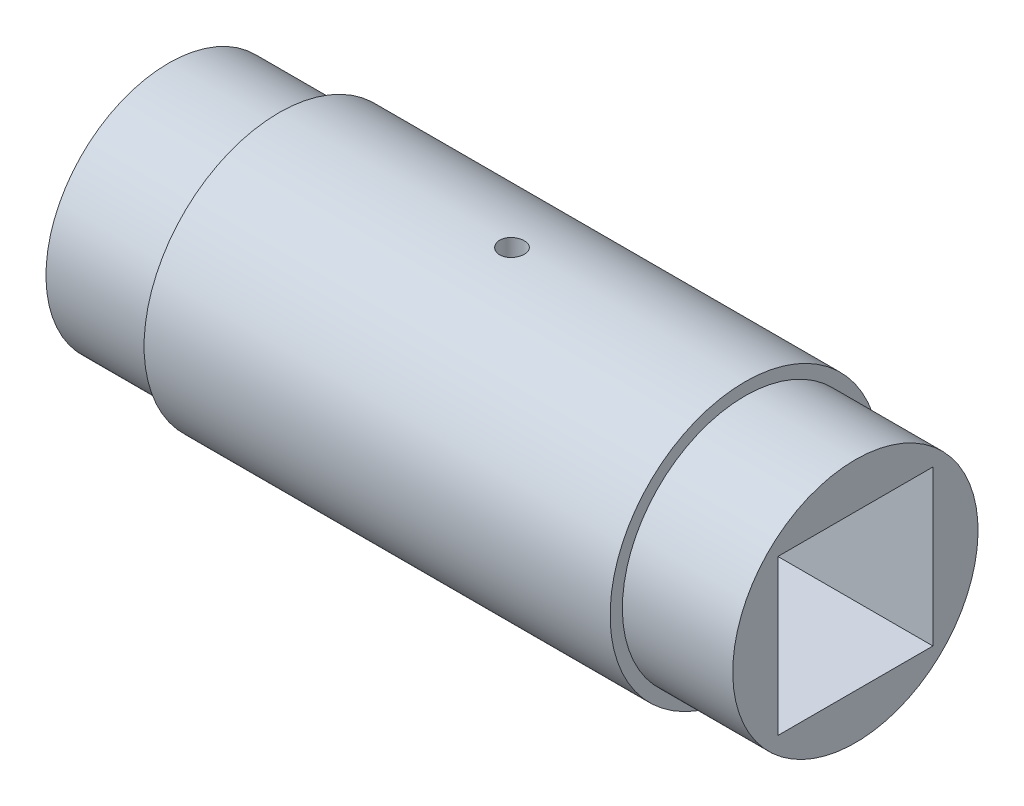
from build123d import *

# Parameters (mm, degrees)
SKETCH2_W          = 6.32
SKETCH2_H          = 6.32
CUT_EXTRUDE1_DEPTH = 29
SKETCH3_R          = 0.5
CUT_EXTRUDE2_DEPTH = 6.5


with BuildPart() as part:
    # Sketch1 → Revolve1 (revolve)
    with BuildSketch(Plane.XY):
        Polygon((-9.5, 5.5), (9.5, 5.5), (9.5, 5), (14, 5), (14, 0), (-14, 0), (-14, 5), (-9.5, 5), align=None)
    revolve(axis=Axis((0, 0, 0), (-1, 0, 0)))

    # Sketch2 → Cut-Extrude1 (cut, through all)
    with BuildSketch(Plane.ZY.offset(14)):
        Rectangle(SKETCH2_W, SKETCH2_H)
    extrude(amount=-CUT_EXTRUDE1_DEPTH, mode=Mode.SUBTRACT)

    # Sketch3 → Cut-Extrude2 (cut, through all)
    with BuildSketch(Plane(origin=(0, 0, 0), x_dir=(1, 0, 0), z_dir=(0, 1, 0))):
        Circle(SKETCH3_R)
    extrude(amount=CUT_EXTRUDE2_DEPTH, mode=Mode.SUBTRACT)


solid = part.part
